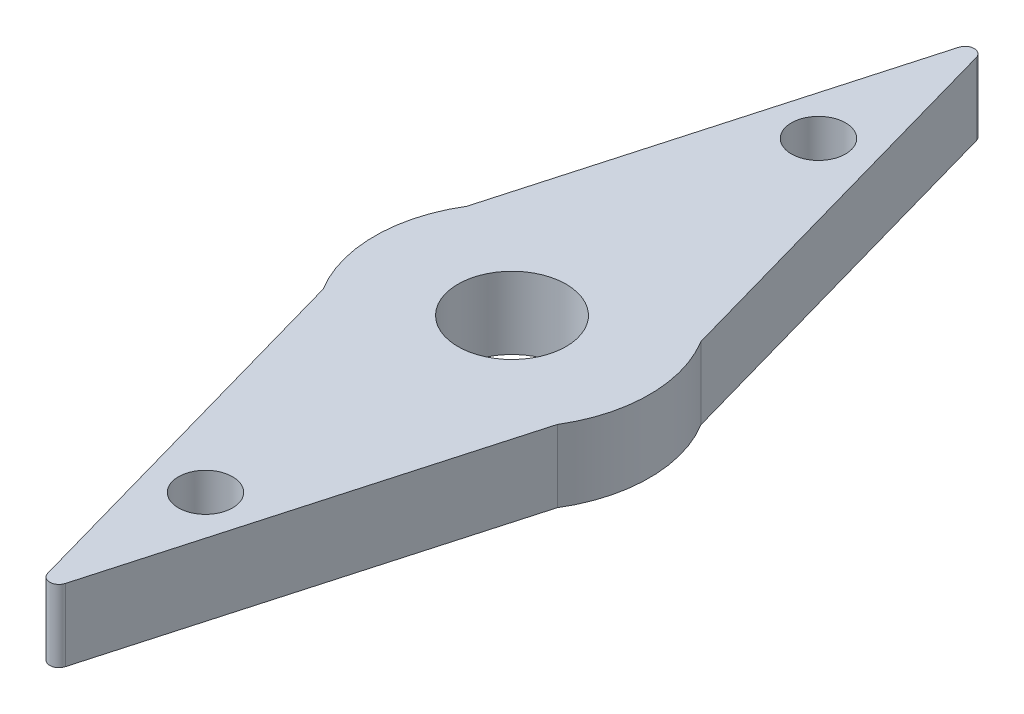
from build123d import *

# Parameters (mm, degrees)
SKETCH1_R           = 3.81
BOSS_EXTRUDE1_DEPTH = 2
BOSS_EXTRUDE2_DEPTH = 2
FILLET1_R           = 0.254
SKETCH3_R           = 0.75
CUT_EXTRUDE1_DEPTH  = 2
SKETCH4_R           = 1.5
CUT_EXTRUDE2_DEPTH  = 3


with BuildPart() as part:
    # Sketch1 → Boss-Extrude1 (new body)
    with BuildSketch(Plane(origin=(0, 0, 0), x_dir=(1, 0, 0), z_dir=(0, 1, 0))):
        Circle(SKETCH1_R)
    extrude(amount=BOSS_EXTRUDE1_DEPTH)

    # Sketch2 → Boss-Extrude2 (add)
    with BuildSketch(Plane(origin=(0, 2, 0), x_dir=(1, 0, 0), z_dir=(0, 1, 0))):
        with BuildLine():
            Line((0, -13.5), (3.247846855, -1.991881223))
            ThreePointArc((3.247846855, -1.991881223), (0, -3.81), (-3.247846855, -1.991881223))
            Line((-3.247846855, -1.991881223), (0, -13.5))
        make_face()
        with BuildLine():
            ThreePointArc((-3.247846855, 1.991881223), (0, 3.81), (3.247846855, 1.991881223))
            Line((3.247846855, 1.991881223), (0, 13.5))
            Line((0, 13.5), (-3.247846855, 1.991881223))
        make_face()
    extrude(amount=-BOSS_EXTRUDE2_DEPTH)

    # Fillet1
    fillet1_edges = [part.edges().sort_by_distance(p)[0] for p in [
        (0, 1, -13.5),
        (0, 1, 13.5),
    ]]
    fillet(fillet1_edges, radius=FILLET1_R)

    # Sketch3 → Cut-Extrude1 (cut)
    with BuildSketch(Plane(origin=(0, 2, 0), x_dir=(1, 0, 0), z_dir=(0, 1, 0))):
        with Locations((0, 8.5)):
            Circle(SKETCH3_R)
        with Locations((0, -8.5)):
            Circle(SKETCH3_R)
    extrude(amount=-CUT_EXTRUDE1_DEPTH, mode=Mode.SUBTRACT)

    # Sketch4 → Cut-Extrude2 (cut, through all)
    with BuildSketch(Plane.XZ):
        Circle(SKETCH4_R)
    extrude(amount=-CUT_EXTRUDE2_DEPTH, mode=Mode.SUBTRACT)


solid = part.part
